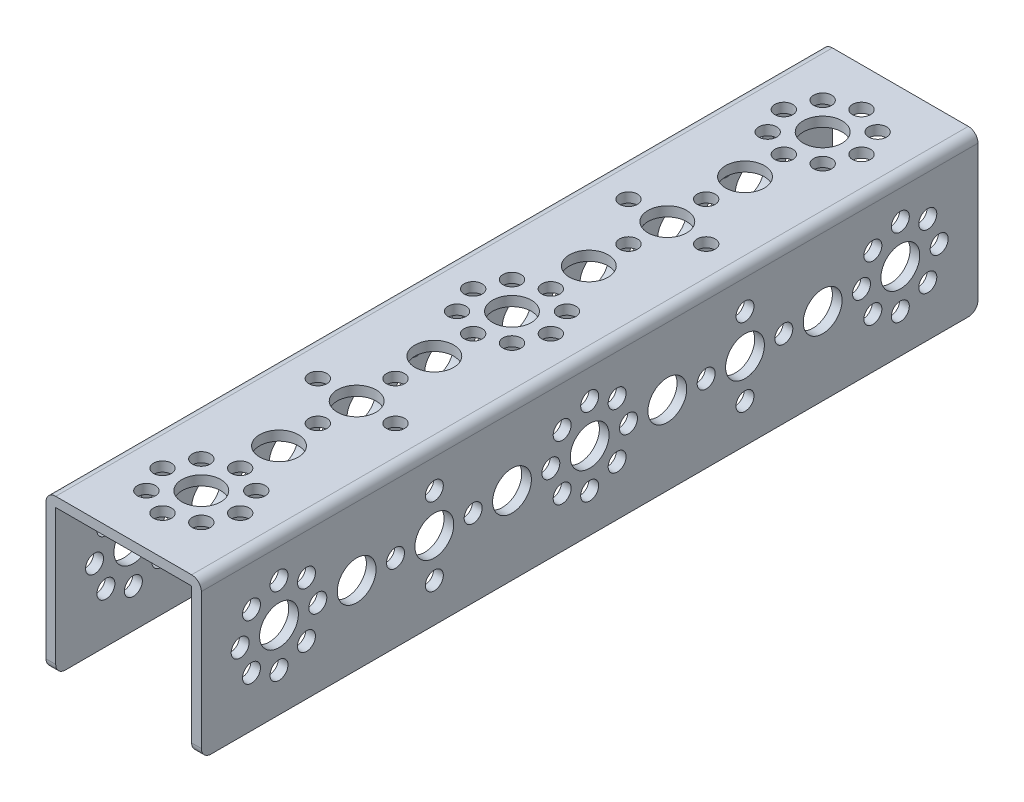
from build123d import *

# Parameters (mm, degrees)
BOSS_EXTRUDE1_DEPTH = 160
SKETCH2_R           = 4
SKETCH2_R_2         = 1.85
CUT_EXTRUDE1_DEPTH  = 33
SKETCH3_R           = 4
SKETCH3_R_2         = 1.85
CUT_EXTRUDE2_DEPTH  = 33
FILLET1_R           = 2


with BuildPart() as part:
    # Sketch1 → Boss-Extrude1 (new body)
    with BuildSketch(Plane.XY):
        Polygon((14, -16), (16, -16), (16, 16), (-16, 16), (-16, -16), (-14, -16), (-14, 14), (14, 14), align=None)
    extrude(amount=-BOSS_EXTRUDE1_DEPTH)

    # Sketch2 → Cut-Extrude1 (cut, through all)
    with BuildSketch(Plane(origin=(0, 16, 0), x_dir=(1, 0, 0), z_dir=(0, 1, 0))):
        with Locations((0, 32)):
            Circle(SKETCH2_R)
        with Locations((0, 64)):
            Circle(SKETCH2_R)
        with Locations((-0.175415159, 96)):
            Circle(SKETCH2_R)
        with Locations((0, 128)):
            Circle(SKETCH2_R)
        with Locations((0, 48)):
            Circle(SKETCH2_R)
        with Locations((0, 56)):
            Circle(SKETCH2_R_2)
        with Locations((0, 40)):
            Circle(SKETCH2_R_2)
        with Locations((8, 48)):
            Circle(SKETCH2_R_2)
        with Locations((-8, 48)):
            Circle(SKETCH2_R_2)
        with Locations((0, 24)):
            Circle(SKETCH2_R_2)
        with Locations((8, 16)):
            Circle(SKETCH2_R_2)
        with Locations((0, 16)):
            Circle(SKETCH2_R)
        with Locations((-8, 16)):
            Circle(SKETCH2_R_2)
        with Locations((-5.66, 10.34)):
            Circle(SKETCH2_R_2)
        with Locations((5.66, 10.34)):
            Circle(SKETCH2_R_2)
        with Locations((0, 8)):
            Circle(SKETCH2_R_2)
        with Locations((-5.66, 21.66)):
            Circle(SKETCH2_R_2)
        with Locations((5.66, 21.66)):
            Circle(SKETCH2_R_2)
        with Locations((0, 112)):
            Circle(SKETCH2_R)
        with Locations((0, 120)):
            Circle(SKETCH2_R_2)
        with Locations((0, 104)):
            Circle(SKETCH2_R_2)
        with Locations((8, 112)):
            Circle(SKETCH2_R_2)
        with Locations((-8, 112)):
            Circle(SKETCH2_R_2)
        with Locations((0, 88)):
            Circle(SKETCH2_R_2)
        with Locations((8, 80)):
            Circle(SKETCH2_R_2)
        with Locations((0, 80)):
            Circle(SKETCH2_R)
        with Locations((-8, 80)):
            Circle(SKETCH2_R_2)
        with Locations((-5.66, 74.34)):
            Circle(SKETCH2_R_2)
        with Locations((5.66, 74.34)):
            Circle(SKETCH2_R_2)
        with Locations((0, 72)):
            Circle(SKETCH2_R_2)
        with Locations((-5.66, 85.66)):
            Circle(SKETCH2_R_2)
        with Locations((5.66, 85.66)):
            Circle(SKETCH2_R_2)
        with Locations((0, 136)):
            Circle(SKETCH2_R_2)
        with Locations((-8, 144)):
            Circle(SKETCH2_R_2)
        with Locations((0, 144)):
            Circle(SKETCH2_R)
        with Locations((8, 144)):
            Circle(SKETCH2_R_2)
        with Locations((5.66, 149.66)):
            Circle(SKETCH2_R_2)
        with Locations((-5.66, 149.66)):
            Circle(SKETCH2_R_2)
        with Locations((0, 152)):
            Circle(SKETCH2_R_2)
        with Locations((5.66, 138.34)):
            Circle(SKETCH2_R_2)
        with Locations((-5.66, 138.34)):
            Circle(SKETCH2_R_2)
    extrude(amount=-CUT_EXTRUDE1_DEPTH, mode=Mode.SUBTRACT)

    # Sketch3 → Cut-Extrude2 (cut, through all)
    with BuildSketch(Plane(origin=(16, 0, 0), x_dir=(0, 0, -1), z_dir=(1, 0, 0))):
        with Locations((32, 0)):
            Circle(SKETCH3_R)
        with Locations((64, 0)):
            Circle(SKETCH3_R)
        with Locations((96, 0.175415159)):
            Circle(SKETCH3_R)
        with Locations((128, 0)):
            Circle(SKETCH3_R)
        with Locations((48, 0)):
            Circle(SKETCH3_R)
        with Locations((56, 0)):
            Circle(SKETCH3_R_2)
        with Locations((40, 0)):
            Circle(SKETCH3_R_2)
        with Locations((48, -8)):
            Circle(SKETCH3_R_2)
        with Locations((48, 8)):
            Circle(SKETCH3_R_2)
        with Locations((24, 0)):
            Circle(SKETCH3_R_2)
        with Locations((16, -8)):
            Circle(SKETCH3_R_2)
        with Locations((16, 0)):
            Circle(SKETCH3_R)
        with Locations((16, 8)):
            Circle(SKETCH3_R_2)
        with Locations((10.34, 5.66)):
            Circle(SKETCH3_R_2)
        with Locations((10.34, -5.66)):
            Circle(SKETCH3_R_2)
        with Locations((8, 0)):
            Circle(SKETCH3_R_2)
        with Locations((21.66, 5.66)):
            Circle(SKETCH3_R_2)
        with Locations((21.66, -5.66)):
            Circle(SKETCH3_R_2)
        with Locations((112, 0)):
            Circle(SKETCH3_R)
        with Locations((120, 0)):
            Circle(SKETCH3_R_2)
        with Locations((104, 0)):
            Circle(SKETCH3_R_2)
        with Locations((112, -8)):
            Circle(SKETCH3_R_2)
        with Locations((112, 8)):
            Circle(SKETCH3_R_2)
        with Locations((88, 0)):
            Circle(SKETCH3_R_2)
        with Locations((80, -8)):
            Circle(SKETCH3_R_2)
        with Locations((80, 0)):
            Circle(SKETCH3_R)
        with Locations((80, 8)):
            Circle(SKETCH3_R_2)
        with Locations((74.34, 5.66)):
            Circle(SKETCH3_R_2)
        with Locations((74.34, -5.66)):
            Circle(SKETCH3_R_2)
        with Locations((72, 0)):
            Circle(SKETCH3_R_2)
        with Locations((85.66, 5.66)):
            Circle(SKETCH3_R_2)
        with Locations((85.66, -5.66)):
            Circle(SKETCH3_R_2)
        with Locations((136, 0)):
            Circle(SKETCH3_R_2)
        with Locations((144, 8)):
            Circle(SKETCH3_R_2)
        with Locations((144, 0)):
            Circle(SKETCH3_R)
        with Locations((144, -8)):
            Circle(SKETCH3_R_2)
        with Locations((149.66, -5.66)):
            Circle(SKETCH3_R_2)
        with Locations((149.66, 5.66)):
            Circle(SKETCH3_R_2)
        with Locations((152, 0)):
            Circle(SKETCH3_R_2)
        with Locations((138.34, -5.66)):
            Circle(SKETCH3_R_2)
        with Locations((138.34, 5.66)):
            Circle(SKETCH3_R_2)
    extrude(amount=-CUT_EXTRUDE2_DEPTH, mode=Mode.SUBTRACT)

    # Fillet1
    fillet1_edges = [part.edges().sort_by_distance(p)[0] for p in [
        (-15, -16, -160),
        (-16, 16, -80),
        (16, 16, -80),
        (15, -16, -160),
        (15, -16, 0),
        (-15, -16, 0),
    ]]
    fillet(fillet1_edges, radius=FILLET1_R)


solid = part.part
